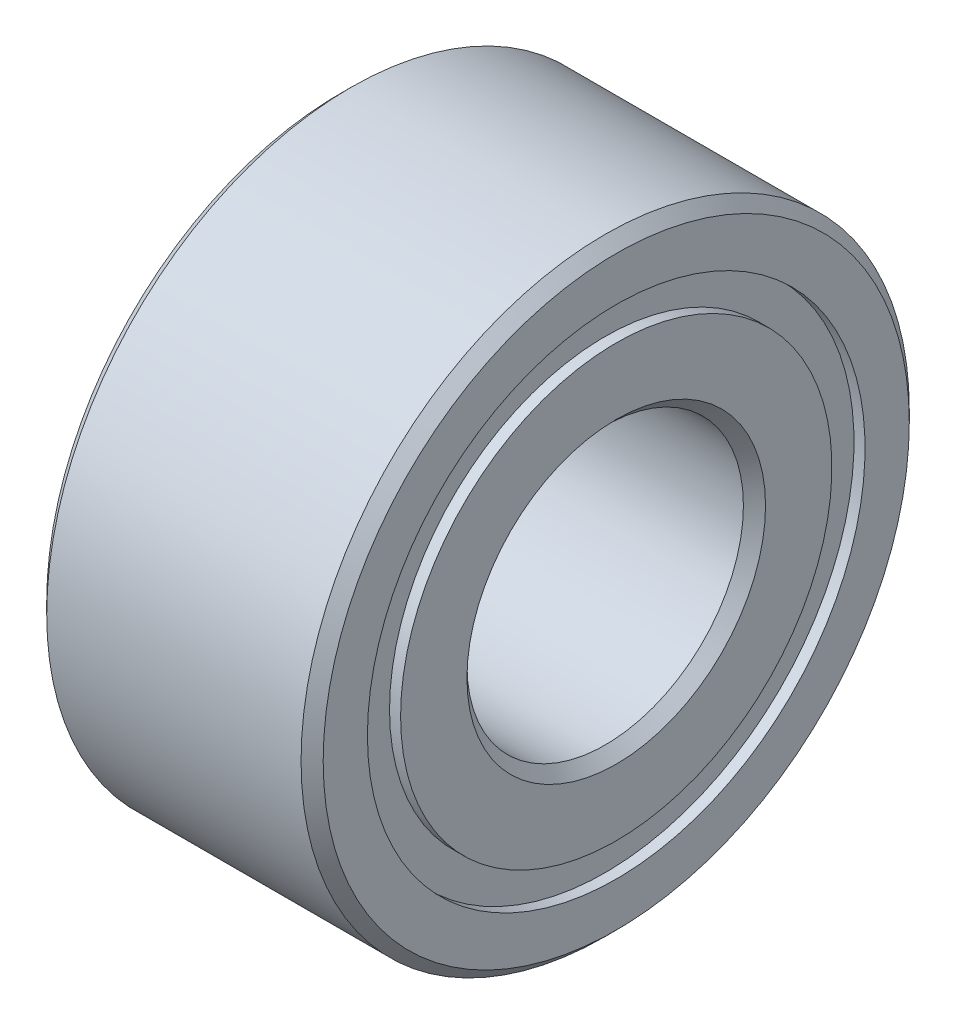
from build123d import *

# Parameters (mm, degrees)
CHAMFER1_SIZE = 0.2


with BuildPart() as part:
    # Sketch1 → Revolve1 (revolve)
    with BuildSketch(Plane.XY):
        Polygon((2.5, 5.5), (-2.5, 5.5), (-2.5, 4.5), (-2.3, 4.5), (-2.3, 3.9), (-2.5, 3.9), (-2.5, 2.5), (2.5, 2.5), (2.5, 3.9), (2.3, 3.9), (2.3, 4.5), (2.5, 4.5), align=None)
    revolve(axis=Axis((-9.578652295, 0, 0), (1, 0, 0)))

    # Chamfer1
    chamfer1_edges = [part.edges().sort_by_distance(p)[0] for p in [
        (2.5, -5.5, 0),
        (-2.5, -5.5, 0),
        (-2.5, -2.5, 0),
        (2.5, -2.5, 0),
    ]]
    chamfer(chamfer1_edges, length=CHAMFER1_SIZE)


solid = part.part
